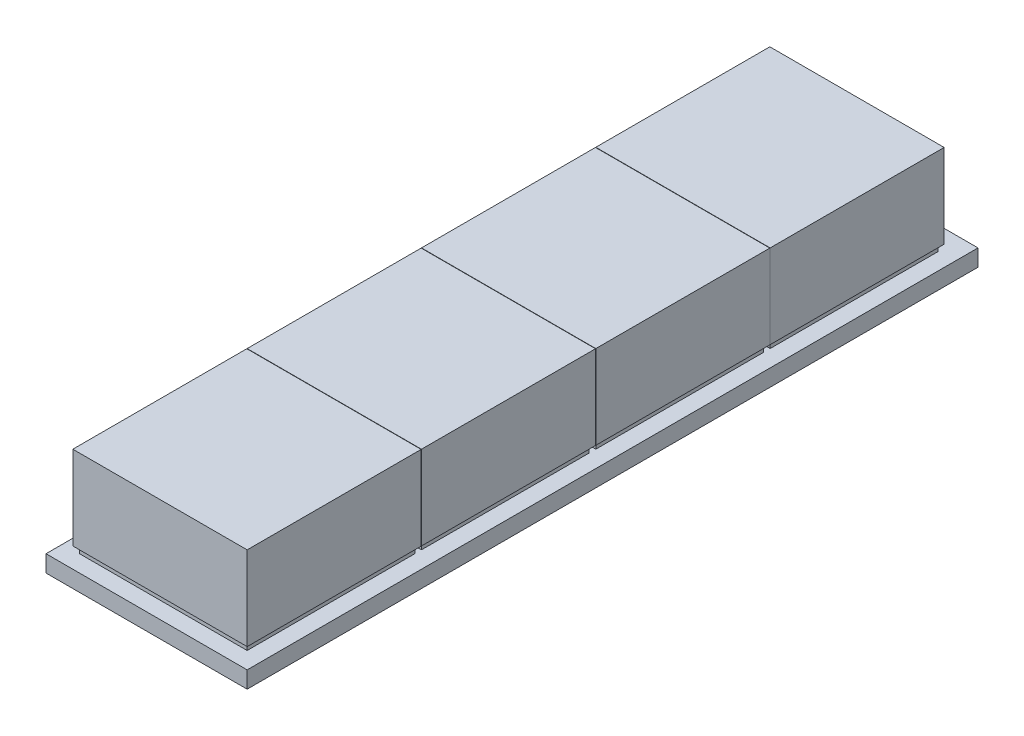
from build123d import *

# Parameters (mm, degrees)
SKETCH1_W           = 60
SKETCH1_H           = 218
BOSS_EXTRUDE1_DEPTH = 5
SKETCH2_W           = 50
SKETCH2_H           = 50
BOSS_EXTRUDE3_DEPTH = 2
LPATTERN1_COUNT     = 4
LPATTERN1_PITCH     = 52
SKETCH3_W           = 52
SKETCH3_H           = 51.9
BOSS_EXTRUDE8_DEPTH = 25
LPATTERN5_COUNT     = 4
LPATTERN5_PITCH     = 52


with BuildPart() as part:
    # Sketch1 → Boss-Extrude1 (new body)
    with BuildSketch(Plane(origin=(0, 0, 0), x_dir=(1, 0, 0), z_dir=(0, 1, 0))):
        Rectangle(SKETCH1_W, SKETCH1_H)
    extrude(amount=BOSS_EXTRUDE1_DEPTH)

    # Sketch2 → Boss-Extrude3 (add)
    with BuildSketch(Plane(origin=(0, 5, 0), x_dir=(1, 0, 0), z_dir=(0, 1, 0))):
        with Locations((0, -79)):
            Rectangle(SKETCH2_W, SKETCH2_H)
    boss_extrude3 = extrude(amount=BOSS_EXTRUDE3_DEPTH)

    # LPattern1: Boss-Extrude3 ×4
    with Locations(*[(0, 0, -i * LPATTERN1_PITCH) for i in range(1, LPATTERN1_COUNT)]):
        add(boss_extrude3)

    # Sketch3 → Boss-Extrude8 (add)
    with BuildSketch(Plane(origin=(0, 7, 0), x_dir=(1, 0, 0), z_dir=(0, 1, 0))):
        with Locations((0, -79.05)):
            Rectangle(SKETCH3_W, SKETCH3_H)
    boss_extrude8 = extrude(amount=BOSS_EXTRUDE8_DEPTH)

    # LPattern5: Boss-Extrude8 ×4
    with Locations(*[(0, 0, -i * LPATTERN5_PITCH) for i in range(1, LPATTERN5_COUNT)]):
        add(boss_extrude8)


solid = part.part
